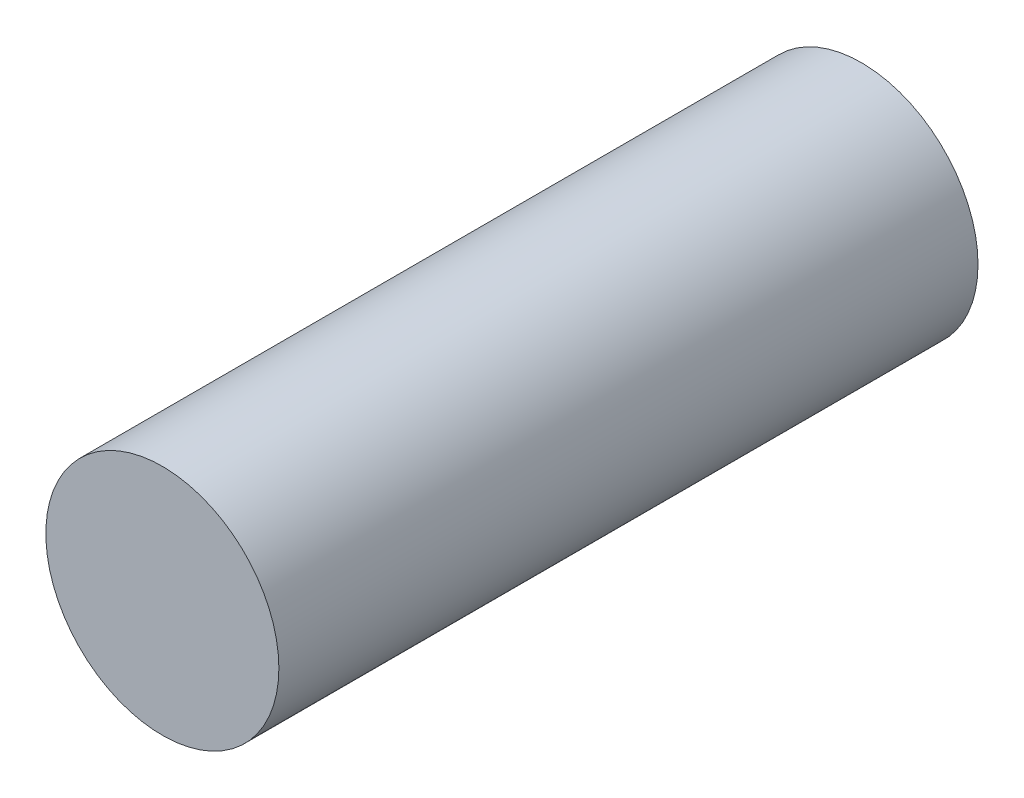
from build123d import *

# Parameters (mm, degrees)
SKETCH_1_R      = 2.5
EXTRUDE_1_DEPTH = 15


with BuildPart() as part:
    # 草圖1 → 填料-伸長1 (new body)
    with BuildSketch(Plane.XY):
        Circle(SKETCH_1_R)
    extrude(amount=EXTRUDE_1_DEPTH)


solid = part.part
